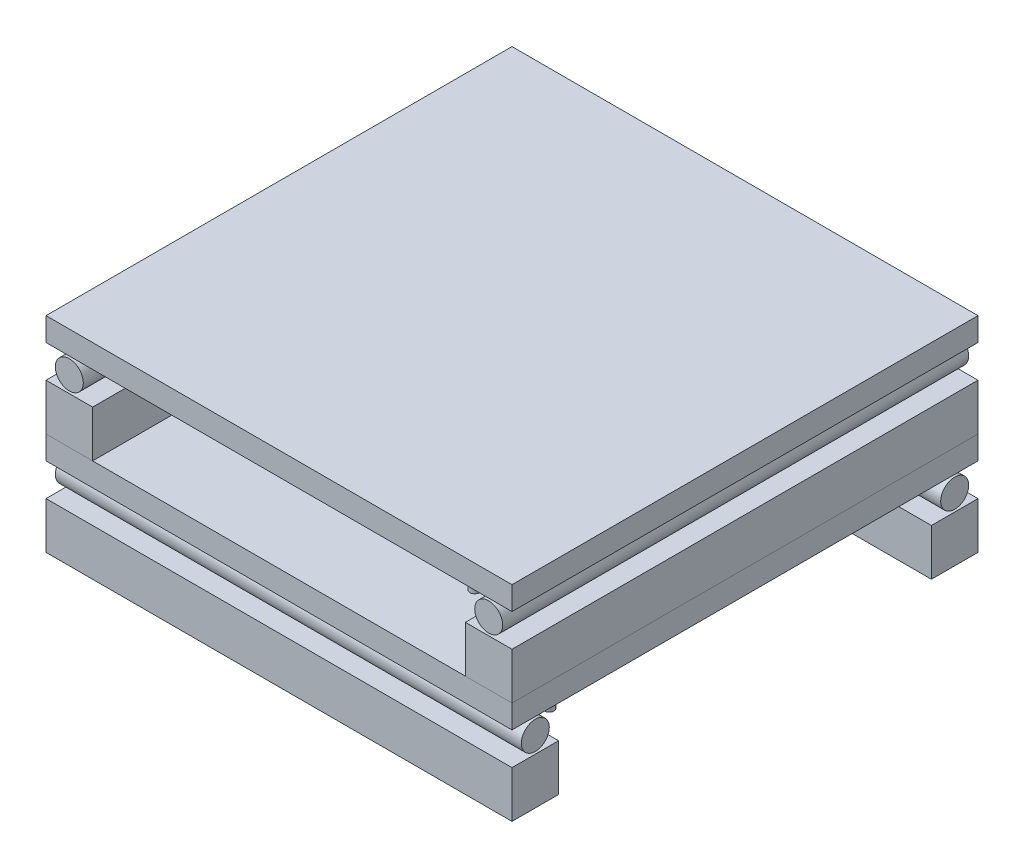
from build123d import *

# Parameters (mm, degrees)
SKETCH1_W             = 100
SKETCH1_H             = 10
BOSS_EXTRUDE1_DEPTH   = 10
BOSS_EXTRUDE1_2_DEPTH = 10
SKETCH2_R             = 3
BOSS_EXTRUDE2_DEPTH   = 100
BOSS_EXTRUDE2_2_DEPTH = 100
SKETCH2_W             = 100
SKETCH2_H             = 5
BOSS_EXTRUDE2_3_DEPTH = 100
SKETCH3_R             = 1
BOSS_EXTRUDE3_DEPTH   = 5
SKETCH6_R             = 1
BOSS_EXTRUDE4_DEPTH   = 2.5
SKETCH7_R             = 3
BOSS_EXTRUDE5_DEPTH   = 5
LPATTERN1_COUNT       = 2
LPATTERN1_PITCH       = 22


with BuildPart() as part:
    # Sketch1 → Boss-Extrude1 (new body)
    with BuildSketch(Plane(origin=(0, 0, 0), x_dir=(1, 0, 0), z_dir=(0, 1, 0))):
        with Locations((0, 45)):
            Rectangle(SKETCH1_W, SKETCH1_H)
    extrude(amount=BOSS_EXTRUDE1_DEPTH)


with BuildPart() as body_2:
    # Sketch1 → Boss-Extrude1 2 (new body)
    with BuildSketch(Plane(origin=(0, 0, 0), x_dir=(1, 0, 0), z_dir=(0, 1, 0))):
        with Locations((0, -45)):
            Rectangle(SKETCH1_W, SKETCH1_H)
    extrude(amount=BOSS_EXTRUDE1_2_DEPTH)


with BuildPart() as body_3:
    # Sketch2 → Boss-Extrude2 (new body)
    with BuildSketch(Plane(origin=(50, 0, 0), x_dir=(0, 0, -1), z_dir=(1, 0, 0))):
        with Locations((-45, 13.5)):
            Circle(SKETCH2_R)
    extrude(amount=-BOSS_EXTRUDE2_DEPTH)


with BuildPart() as body_4:
    # Sketch2 → Boss-Extrude2 2 (new body)
    with BuildSketch(Plane(origin=(50, 0, 0), x_dir=(0, 0, -1), z_dir=(1, 0, 0))):
        with Locations((45, 13.5)):
            Circle(SKETCH2_R)
    extrude(amount=-BOSS_EXTRUDE2_2_DEPTH)


with BuildPart() as body_5:
    # Sketch2 → Boss-Extrude2 3 (new body)
    with BuildSketch(Plane(origin=(50, 0, 0), x_dir=(0, 0, -1), z_dir=(1, 0, 0))):
        with Locations((0, 19.5)):
            Rectangle(SKETCH2_W, SKETCH2_H)
    extrude(amount=-BOSS_EXTRUDE2_3_DEPTH)

    # Sketch3 → Boss-Extrude3 (add)
    with BuildSketch(Plane.XZ.offset(-17)):
        with Locations((45, 37)):
            Circle(SKETCH3_R)
        with Locations((-45, 37)):
            Circle(SKETCH3_R)
    extrude(amount=BOSS_EXTRUDE3_DEPTH)


with BuildPart() as body_6:
    # Sketch6 → Boss-Extrude4 (new body, symmetric)
    with BuildSketch(Plane.XZ.offset(-12)):
        with Locations((24.312031504, 37)):
            Circle(SKETCH6_R)
    extrude(amount=BOSS_EXTRUDE4_DEPTH, both=True)

    # Sketch7 → Boss-Extrude5 (add)
    with BuildSketch(Plane.XZ.offset(-9.5)):
        with Locations((24.312031504, 37)):
            Circle(SKETCH7_R)
    extrude(amount=BOSS_EXTRUDE5_DEPTH)


with BuildPart() as lpattern1_1:
    # LPattern1: pattern copy
    add(body_2.part.moved(Location(Vector(0, 1, 0) * (1 * LPATTERN1_PITCH))))


with BuildPart() as lpattern1_2:
    # LPattern1: pattern copy
    add(body_6.part.moved(Location(Vector(0, 1, 0) * (1 * LPATTERN1_PITCH))))


with BuildPart() as lpattern1_3:
    # LPattern1: pattern copy
    add(body_3.part.moved(Location(Vector(0, 1, 0) * (1 * LPATTERN1_PITCH))))


with BuildPart() as lpattern1_4:
    # LPattern1: pattern copy
    add(body_5.part.moved(Location(Vector(0, 1, 0) * (1 * LPATTERN1_PITCH))))


with BuildPart() as lpattern1_5:
    # LPattern1: pattern copy
    add(part.part.moved(Location(Vector(0, 1, 0) * (1 * LPATTERN1_PITCH))))


with BuildPart() as lpattern1_6:
    # LPattern1: pattern copy
    add(body_4.part.moved(Location(Vector(0, 1, 0) * (1 * LPATTERN1_PITCH))))


with BuildPart() as body_13:
    # Mirror2: mirrored copy
    add(lpattern1_2.part.mirror(Plane(origin=(0, 0, 0), x_dir=(0.707106781, 0, 0.707106781), z_dir=(-0.707106781, 0, 0.707106781))))


with BuildPart() as body_14:
    # Mirror2 2: mirrored copy
    add(lpattern1_3.part.mirror(Plane(origin=(0, 0, 0), x_dir=(0.707106781, 0, 0.707106781), z_dir=(-0.707106781, 0, 0.707106781))))


with BuildPart() as body_15:
    # Mirror2 3: mirrored copy
    add(lpattern1_4.part.mirror(Plane(origin=(0, 0, 0), x_dir=(0.707106781, 0, 0.707106781), z_dir=(-0.707106781, 0, 0.707106781))))


with BuildPart() as body_16:
    # Mirror2 4: mirrored copy
    add(lpattern1_6.part.mirror(Plane(origin=(0, 0, 0), x_dir=(0.707106781, 0, 0.707106781), z_dir=(-0.707106781, 0, 0.707106781))))


with BuildPart() as body_17:
    # Mirror2 5: mirrored copy
    add(lpattern1_5.part.mirror(Plane(origin=(0, 0, 0), x_dir=(0.707106781, 0, 0.707106781), z_dir=(-0.707106781, 0, 0.707106781))))


with BuildPart() as body_18:
    # Mirror2 6: mirrored copy
    add(lpattern1_1.part.mirror(Plane(origin=(0, 0, 0), x_dir=(0.707106781, 0, 0.707106781), z_dir=(-0.707106781, 0, 0.707106781))))


solid = Compound([part.part, body_2.part, body_3.part, body_4.part, body_5.part, body_6.part, body_13.part, body_14.part, body_15.part, body_16.part, body_17.part, body_18.part])
